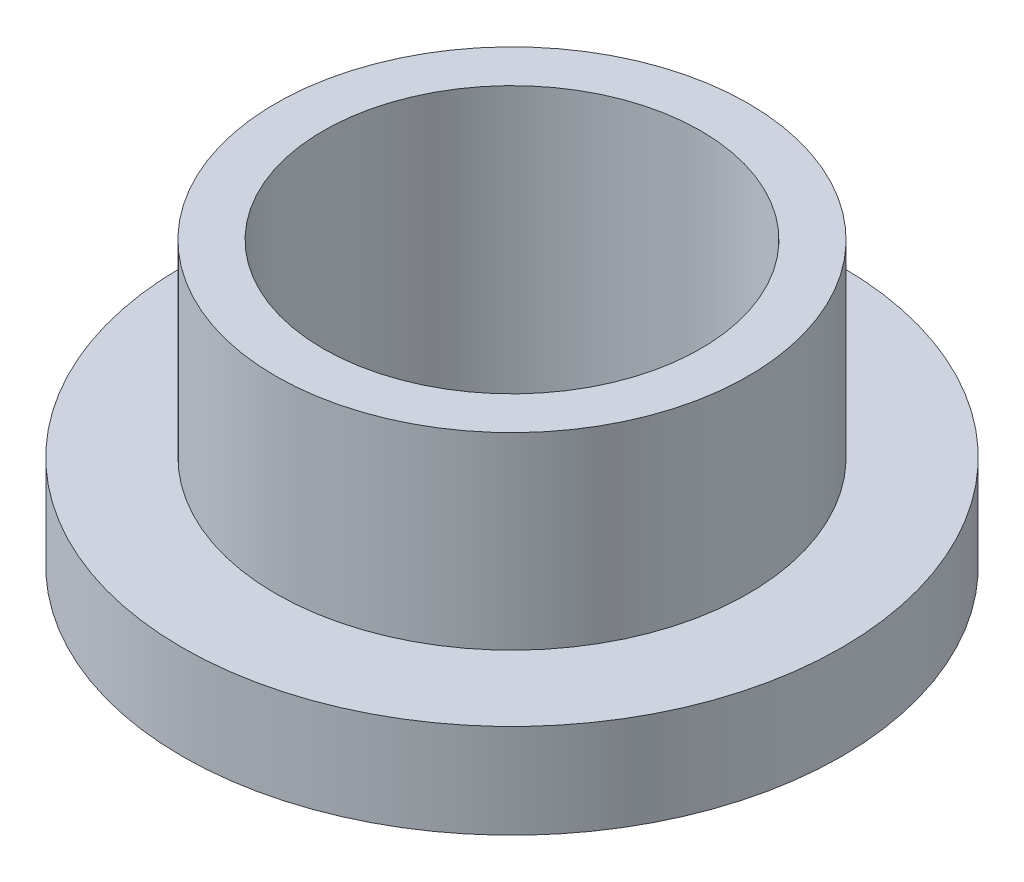
from build123d import *

# Parameters (mm, degrees)
SKETCH2_R           = 7.9629
SKETCH2_R_2         = 6.3627
BOSS_EXTRUDE1_DEPTH = 9.525
SKETCH3_R           = 11.1125
SKETCH3_R_2         = 7.9629
BOSS_EXTRUDE2_DEPTH = 3.175


with BuildPart() as part:
    # Sketch2 → Boss-Extrude1 (new body)
    with BuildSketch(Plane(origin=(0, 0, 0), x_dir=(1, 0, 0), z_dir=(0, 1, 0))):
        Circle(SKETCH2_R)
        Circle(SKETCH2_R_2, mode=Mode.SUBTRACT)
    extrude(amount=BOSS_EXTRUDE1_DEPTH)

    # Sketch3 → Boss-Extrude2 (add)
    with BuildSketch(Plane(origin=(0, 0, 0), x_dir=(1, 0, 0), z_dir=(0, 1, 0))):
        Circle(SKETCH3_R)
        Circle(SKETCH3_R_2, mode=Mode.SUBTRACT)
    extrude(amount=BOSS_EXTRUDE2_DEPTH)


solid = part.part
